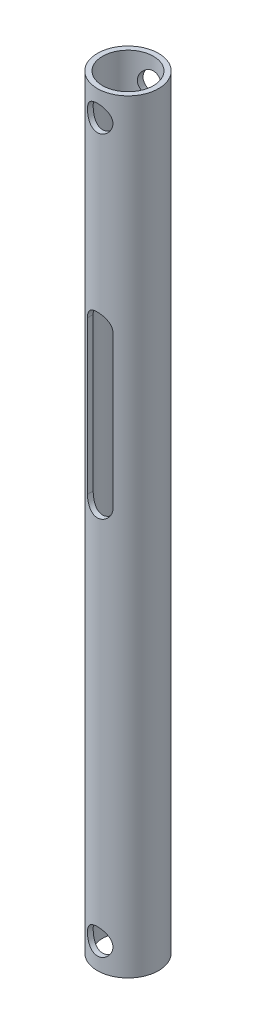
from build123d import *

# Parameters (mm, degrees)
SZKIC1_R                        = 6
SZKIC1_R_2                      = 5
DODANIE_WYCI_GNI_CIE1_DEPTH     = 150
SZKIC3_R                        = 2.5
WYTNIJ_WYCI_GNI_CIE2_DEPTH      = 7
WYTNIJ_WYCI_GNI_CIE2_DEPTH_BACK = 7


with BuildPart() as part:
    # Szkic1 → Dodanie-wyciągnięcie1 (new body)
    with BuildSketch(Plane(origin=(0, 0, 0), x_dir=(1, 0, 0), z_dir=(0, 1, 0))):
        Circle(SZKIC1_R)
        Circle(SZKIC1_R_2, mode=Mode.SUBTRACT)
    extrude(amount=DODANIE_WYCI_GNI_CIE1_DEPTH)

    # Szkic3 → Wytnij-wyciągnięcie2 (cut, two sides)
    with BuildSketch(Plane.XY) as wytnij_wyci_gni_cie2_sk:
        with Locations((0, 145)):
            Circle(SZKIC3_R)
        with Locations((0, 5)):
            Circle(SZKIC3_R)
        with BuildLine():
            Line((-2.5, 79.5), (-2.5, 109.5))
            ThreePointArc((-2.5, 109.5), (0, 112), (2.5, 109.5))
            Line((2.5, 109.5), (2.5, 79.5))
            ThreePointArc((2.5, 79.5), (0, 77), (-2.5, 79.5))
        make_face()
    extrude(amount=WYTNIJ_WYCI_GNI_CIE2_DEPTH, mode=Mode.SUBTRACT)
    extrude(wytnij_wyci_gni_cie2_sk.sketch, amount=-WYTNIJ_WYCI_GNI_CIE2_DEPTH_BACK, mode=Mode.SUBTRACT)


solid = part.part
